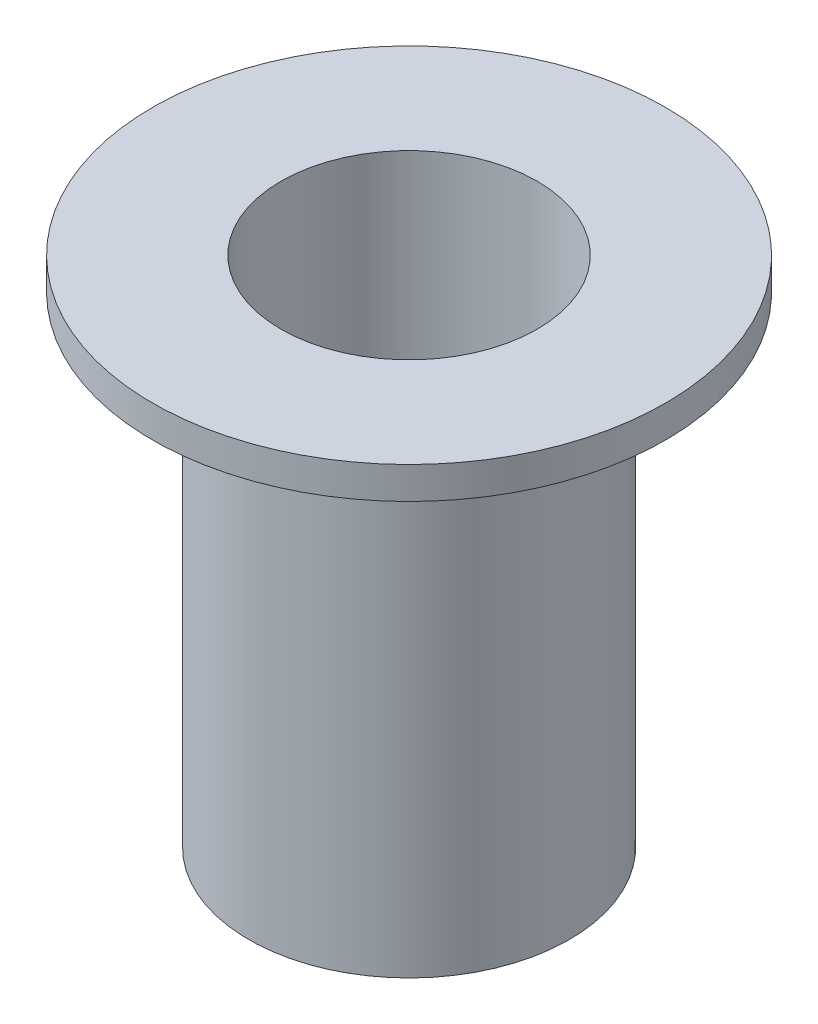
from build123d import *


with BuildPart() as part:
    # Sketch1 → Revolve1 (revolve)
    with BuildSketch(Plane(origin=(0, 0, 0), x_dir=(0, 0, -1), z_dir=(1, 0, 0))):
        Polygon((3.175, 0), (3.175, 12.7), (6.35, 12.7), (6.35, 11.90625), (3.96875, 11.90625), (3.96875, 0), align=None)
    revolve(axis=Axis((0, 0, 0), (0, 1, 0)))


solid = part.part
